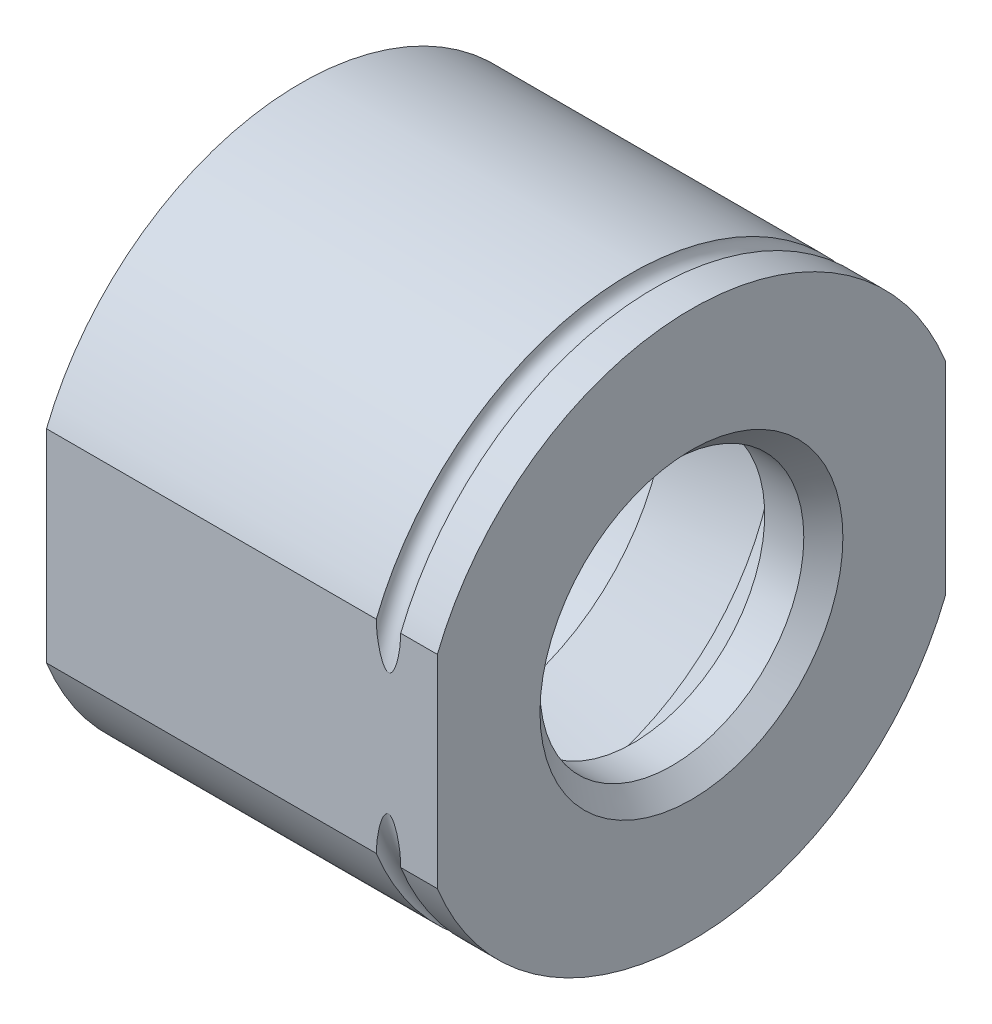
from build123d import *

# Parameters (mm, degrees)
BOSS_EXTRUDE1_DEPTH = 2.032
CHAMFER1_SIZE       = 0.1016


with BuildPart() as part:
    # Sketch1 → Boss-Extrude1 (new body)
    with BuildSketch(Plane(origin=(1.9304, 0, 0), x_dir=(0, 0, -1), z_dir=(1, 0, 0))):
        with BuildLine():
            Line((1.3208, -0.527317703), (1.3208, 0.527317703))
            ThreePointArc((1.3208, 0.527317703), (0, 1.422173196), (-1.3208, 0.527317703))
            Line((-1.3208, 0.527317703), (-1.3208, -0.527317703))
            ThreePointArc((-1.3208, -0.527317703), (0, -1.422173196), (1.3208, -0.527317703))
        make_face()
    extrude(amount=-BOSS_EXTRUDE1_DEPTH)

    # Sketch2 → Cut-Revolve1 (revolve, cut)
    with BuildSketch(Plane(origin=(0, 0, 0), x_dir=(-1, 0, 0), z_dir=(0, 0, -1))):
        Polygon((-1.9304, 0.6858), (-1.9304, 0), (0.1016, 0), (0.1016, 1.1049), (-0.8128, 1.1049), (-0.8128, 0.987363608), (-1.2192, 1.1557), (-1.6256, 0.987363608), (-1.6256, 0.6858), align=None)
    revolve(axis=Axis((1.9304, 0, 0), (-1, 0, 0)), mode=Mode.SUBTRACT)

    # Chamfer1
    chamfer1_edges = [part.edges().sort_by_distance(p)[0] for p in [
        (1.9304, -0.6858, 0),
    ]]
    chamfer(chamfer1_edges, length=CHAMFER1_SIZE)

    # Sketch3 → Cut-Revolve2 (revolve, cut)
    with BuildSketch(Plane.XY):
        with BuildLine():
            Line((1.7399, 1.422173196), (1.6129, 1.422173196))
            ThreePointArc((1.6129, 1.422173196), (1.6764, 1.358673196), (1.7399, 1.422173196))
        make_face()
    revolve(axis=Axis((-0.1016, 0, 0), (1, 0, 0)), mode=Mode.SUBTRACT)


solid = part.part
